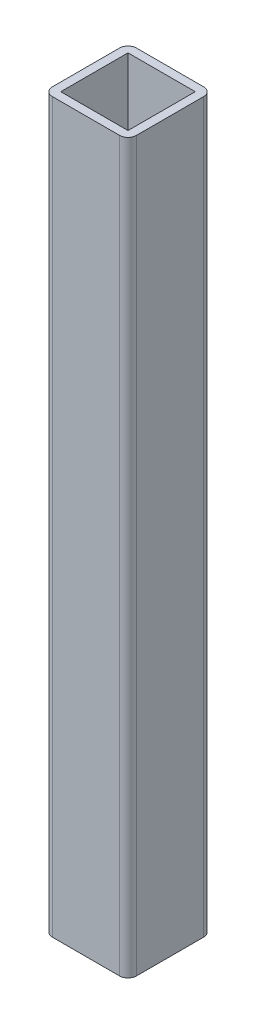
from build123d import *

# Parameters (mm, degrees)
CROQUIS1_W              = 24
CROQUIS1_H              = 24
SALIENTE_EXTRUIR1_DEPTH = 259.715457153


with BuildPart() as part:
    # Croquis1 → Saliente-Extruir1 (new body)
    with BuildSketch(Plane(origin=(0, 647.649993896, 0), x_dir=(1, 0, 0), z_dir=(0, 1, 0))):
        with BuildLine():
            Line((-12, 50.120137415), (12, 50.120137415))
            ThreePointArc((12, 50.120137415), (14.121320344, 50.998817072), (15, 53.120137415))
            Line((15, 53.120137415), (15, 77.120137415))
            ThreePointArc((15, 77.120137415), (14.121320344, 79.241457759), (12, 80.120137415))
            Line((12, 80.120137415), (-12, 80.120137415))
            ThreePointArc((-12, 80.120137415), (-14.121320344, 79.241457759), (-15, 77.120137415))
            Line((-15, 77.120137415), (-15, 53.120137415))
            ThreePointArc((-15, 53.120137415), (-14.121320344, 50.998817072), (-12, 50.120137415))
        make_face()
        with Locations((0, 65.120137415)):
            Rectangle(CROQUIS1_W, CROQUIS1_H, mode=Mode.SUBTRACT)
    extrude(amount=-SALIENTE_EXTRUIR1_DEPTH)


solid = part.part
